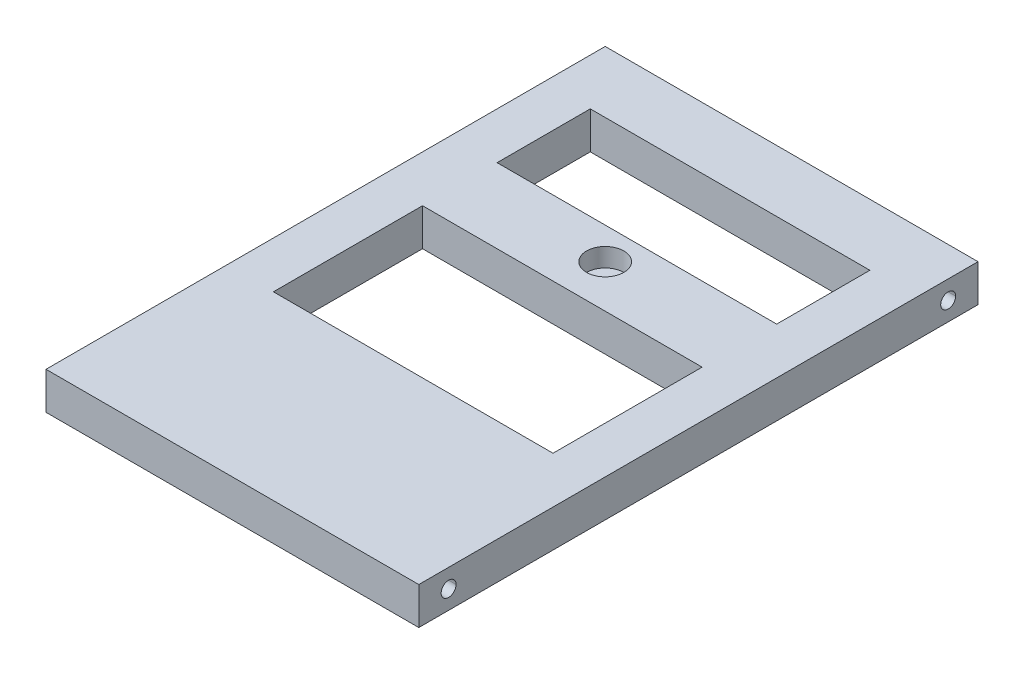
from build123d import *

# Parameters (mm, degrees)
SKETCH2_W           = 100
SKETCH2_H           = 150
BOSS_EXTRUDE1_DEPTH = 10
SKETCH3_R           = 5
MOUNTHOLE_DEPTH     = 5
SKETCH4_R           = 2
CUT_EXTRUDE2_DEPTH  = 101
SKETCH5_R           = 2
CUT_EXTRUDE3_DEPTH  = 101
SKETCH14_W          = 75
SKETCH14_H          = 25
SKETCH14_H_2        = 40
CUT_EXTRUDE7_DEPTH  = 11


with BuildPart() as part:
    # Sketch2 → Boss-Extrude1 (new body)
    with BuildSketch(Plane(origin=(0, 0, 0), x_dir=(1, 0, 0), z_dir=(0, 1, 0))):
        with Locations((50, 75)):
            Rectangle(SKETCH2_W, SKETCH2_H)
    extrude(amount=BOSS_EXTRUDE1_DEPTH)

    # Sketch3 → MountHole (cut)
    with BuildSketch(Plane(origin=(0, 10, 0), x_dir=(1, 0, 0), z_dir=(0, 1, 0))):
        with Locations((50, 100)):
            Circle(SKETCH3_R)
    extrude(amount=-MOUNTHOLE_DEPTH, mode=Mode.SUBTRACT)

    # Sketch4 → Cut-Extrude2 (cut, through all)
    with BuildSketch(Plane.ZY):
        with Locations((-8, 5)):
            Circle(SKETCH4_R)
    extrude(amount=-CUT_EXTRUDE2_DEPTH, mode=Mode.SUBTRACT)

    # Sketch5 → Cut-Extrude3 (cut, through all)
    with BuildSketch(Plane.ZY):
        with Locations((-142, 5)):
            Circle(SKETCH5_R)
    extrude(amount=-CUT_EXTRUDE3_DEPTH, mode=Mode.SUBTRACT)

    # Sketch14 → Cut-Extrude7 (cut, through all)
    with BuildSketch(Plane(origin=(0, 10, 0), x_dir=(1, 0, 0), z_dir=(0, 1, 0))):
        with Locations((50, 121)):
            Rectangle(SKETCH14_W, SKETCH14_H)
        with Locations((50, 68.5)):
            Rectangle(SKETCH14_W, SKETCH14_H_2)
    extrude(amount=-CUT_EXTRUDE7_DEPTH, mode=Mode.SUBTRACT)


solid = part.part
